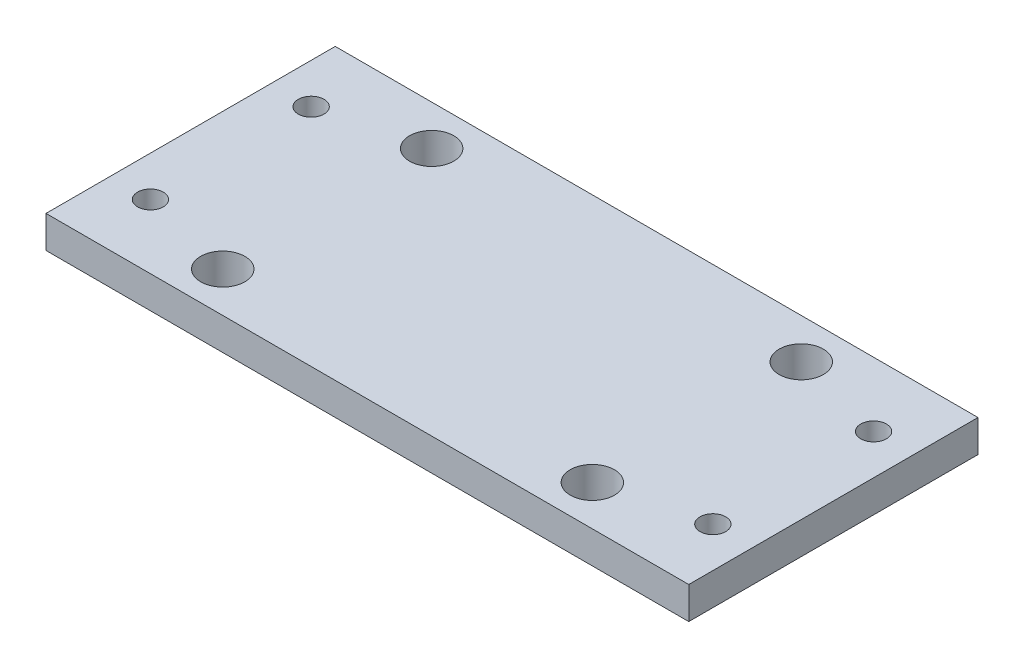
from build123d import *

# Parameters (mm, degrees)
SKETCH_1_R      = 2.75
SKETCH_1_R_2    = 1.6
EXTRUDE_1_DEPTH = 4


with BuildPart() as part:
    # 草图1 → 凸台-拉伸1 (new body)
    with BuildSketch(Plane(origin=(0, 0, 0), x_dir=(1, 0, 0), z_dir=(0, 1, 0))):
        Polygon((-34.919077445, 32.481158859), (33.080922555, 32.481158859), (33.080922555, -3.518841141), (-34.919077445, -3.518841141), (-46.919077445, -3.518841141), (-46.919077445, 32.481158859), align=None)
        with Locations((-29.919077445, 27.481158859)):
            Circle(SKETCH_1_R, mode=Mode.SUBTRACT)
        with Locations((16.080922555, 27.481158859)):
            Circle(SKETCH_1_R, mode=Mode.SUBTRACT)
        with Locations((-29.919077445, 1.481158859)):
            Circle(SKETCH_1_R, mode=Mode.SUBTRACT)
        with Locations((16.080922555, 1.481158859)):
            Circle(SKETCH_1_R, mode=Mode.SUBTRACT)
        with Locations((-41.919077445, 24.481158859)):
            Circle(SKETCH_1_R_2, mode=Mode.SUBTRACT)
        with Locations((28.080922555, 24.481158859)):
            Circle(SKETCH_1_R_2, mode=Mode.SUBTRACT)
        with Locations((-41.919077445, 4.481158859)):
            Circle(SKETCH_1_R_2, mode=Mode.SUBTRACT)
        with Locations((28.080922555, 4.481158859)):
            Circle(SKETCH_1_R_2, mode=Mode.SUBTRACT)
    extrude(amount=EXTRUDE_1_DEPTH)


solid = part.part
